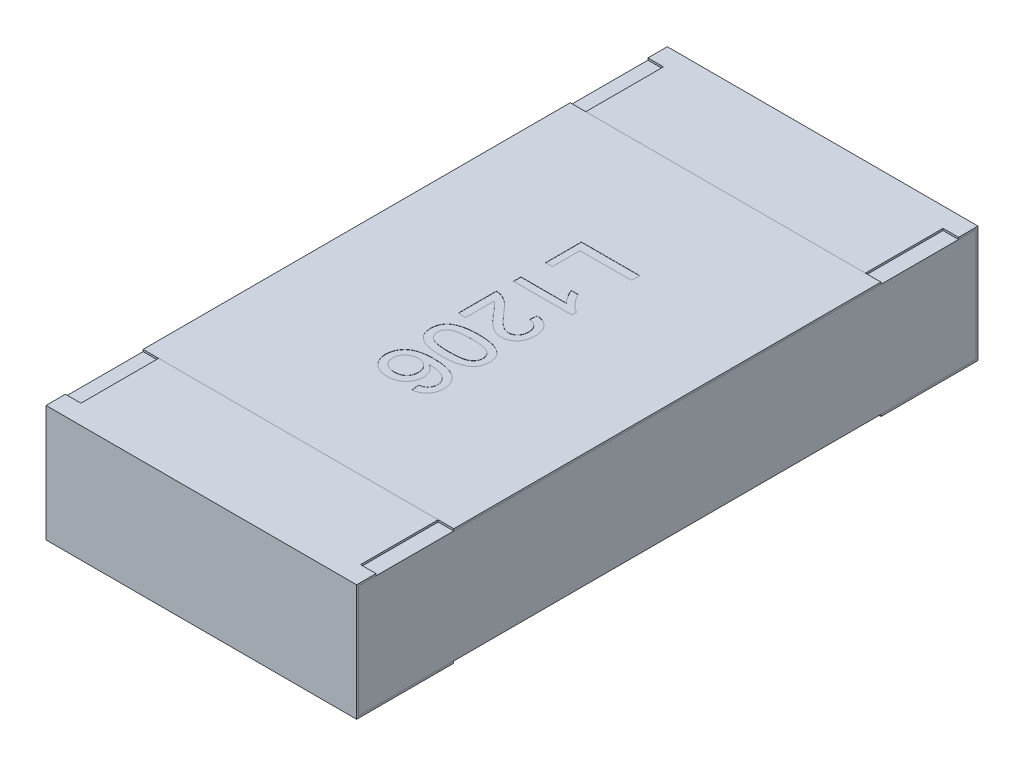
from build123d import *

# Parameters (mm, degrees)
BOSS_EXTRUDE2_DEPTH   = 0.8
BOSS_EXTRUDE2_2_DEPTH = 0.8
BOSS_EXTRUDE3_START   = -0.8
SKETCH5_W             = 3.18
SKETCH5_H             = 0.58
BOSS_EXTRUDE3_DEPTH   = 1.6
SKETCH6_W             = 0.08
SKETCH6_H             = 0.4
CUT_EXTRUDE1_DEPTH    = 0.01
SKETCH7_W             = 1.6
SKETCH7_H             = 2.2
BOSS_EXTRUDE4_DEPTH   = 0.01
TEXT1206_DEPTH        = 0.001


with BuildPart() as part:
    # Sketch4 → Boss-Extrude2 (new body, symmetric)
    with BuildSketch(Plane(origin=(0, 0, 0), x_dir=(0, 0, -1), z_dir=(1, 0, 0))):
        Polygon((-1.6, 0.3), (-1.6, -0.3), (-1.1, -0.3), (-1.1, -0.29), (-1.59, -0.29), (-1.59, 0.29), (-1.1, 0.29), (-1.1, 0.3), align=None)
    extrude(amount=BOSS_EXTRUDE2_DEPTH, both=True)


with BuildPart() as body_2:
    # Sketch4 → Boss-Extrude2 2 (new body, symmetric)
    with BuildSketch(Plane(origin=(0, 0, 0), x_dir=(0, 0, -1), z_dir=(1, 0, 0))):
        Polygon((1.1, 0.3), (1.6, 0.3), (1.6, -0.3), (1.1, -0.3), (1.1, -0.29), (1.59, -0.29), (1.59, 0.29), (1.1, 0.29), align=None)
    extrude(amount=BOSS_EXTRUDE2_2_DEPTH, both=True)


with BuildPart() as body_3:
    # Sketch5 → Boss-Extrude3 (new body)
    with BuildSketch(Plane(origin=(0, 0, 0), x_dir=(0, 0, -1), z_dir=(1, 0, 0)).offset(BOSS_EXTRUDE3_START)):
        Rectangle(SKETCH5_W, SKETCH5_H)
    extrude(amount=BOSS_EXTRUDE3_DEPTH)


with BuildPart() as cut_extrude1_tool:
    # Sketch6 → Cut-Extrude1 (new body)
    with BuildSketch(Plane(origin=(0, 0.3, 0), x_dir=(1, 0, 0), z_dir=(0, 1, 0))):
        with Locations((-0.76, 1.3)):
            Rectangle(SKETCH6_W, SKETCH6_H)
        with Locations((0.76, 1.3)):
            Rectangle(SKETCH6_W, SKETCH6_H)
        with Locations((0.76, -1.3)):
            Rectangle(SKETCH6_W, SKETCH6_H)
        with Locations((-0.76, -1.3)):
            Rectangle(SKETCH6_W, SKETCH6_H)
    extrude(amount=-CUT_EXTRUDE1_DEPTH)


with BuildPart() as part_1:
    add(part.part)

    # Cut-Extrude1: cut by cut_extrude1_tool
    add(cut_extrude1_tool.part, mode=Mode.SUBTRACT)


with BuildPart() as body_2_1:
    add(body_2.part)

    # Cut-Extrude1: cut by cut_extrude1_tool
    add(cut_extrude1_tool.part, mode=Mode.SUBTRACT)


with BuildPart() as body_4:
    # Sketch7 → Boss-Extrude4 (new body)
    with BuildSketch(Plane(origin=(0, 0.29, 0), x_dir=(1, 0, 0), z_dir=(0, 1, 0))):
        Rectangle(SKETCH7_W, SKETCH7_H)
    extrude(amount=BOSS_EXTRUDE4_DEPTH)

    # Sketch12 → TEXT1206 (cut)
    with BuildSketch(Plane(origin=(0, 0.3, 0), x_dir=(1, 0, 0), z_dir=(0, 1, 0))):
        Polygon((-0.15, 0.507688704), (0.15, 0.507688704), (0.15, 0.465381012), (-0.115384615, 0.465381012), (-0.115384615, 0.323073319), (-0.15, 0.323073319), align=None)
        with BuildLine():
            Line((-0.15, 0.157688704), (-0.15, 0.196150243))
            Line((-0.15, 0.196150243), (0.083774038, 0.196150243))
            add(Edge.make_bspline(
                [(0.083774038, 0.196150243), (0.081638509, 0.198364988), (0.077200045, 0.202968095), (0.070914564, 0.210746555), (0.064571645, 0.219426408), (0.058389404, 0.228863662), (0.052683492, 0.2385576), (0.047476916, 0.247897164), (0.043093554, 0.256751905), (0.040694469, 0.262582976), (0.039543269, 0.265381012)],
                knots=[0, 0, 0, 0, 9.226e-06, 1.9175e-05, 2.9969e-05, 4.147e-05, 5.3003e-05, 6.3709e-05, 7.3546e-05, 8.262e-05, 8.262e-05, 8.262e-05, 8.262e-05], degree=3))
            Line((0.039543269, 0.265381012), (0.075, 0.265381012))
            add(Edge.make_bspline(
                [(0.075, 0.265381012), (0.077475162, 0.260574892), (0.082353558, 0.251102313), (0.09077922, 0.237719608), (0.099912985, 0.225225413), (0.10975283, 0.213826557), (0.119810917, 0.203608209), (0.129959923, 0.194997059), (0.139827828, 0.187791796), (0.146709597, 0.184176779), (0.15, 0.182448319)],
                knots=[0, 0, 0, 0, 1.6212e-05, 3.1953e-05, 4.7386e-05, 6.26e-05, 7.7091e-05, 9.0349e-05, 0.000102505, 0.000113642, 0.000113642, 0.000113642, 0.000113642], degree=3))
            Line((0.15, 0.182448319), (0.15, 0.157688704))
            Line((0.15, 0.157688704), (-0.15, 0.157688704))
        make_face()
        with BuildLine():
            Line((-0.111538462, -0.126926681), (-0.15, -0.126926681))
            Line((-0.15, -0.126926681), (-0.15, 0.069227166))
            add(Edge.make_bspline(
                [(-0.15, 0.069227166), (-0.147714123, 0.069231181), (-0.14315003, 0.0692392), (-0.136400026, 0.068466881), (-0.129739566, 0.067257277), (-0.125468478, 0.065889577), (-0.123317308, 0.065200723)],
                knots=[0, 0, 0, 0, 6.852e-06, 1.3681e-05, 2.0352e-05, 2.7121e-05, 2.7121e-05, 2.7121e-05, 2.7121e-05], degree=3))
            add(Edge.make_bspline(
                [(-0.123317308, 0.065200723), (-0.119803316, 0.063926707), (-0.112648251, 0.061332599), (-0.102300861, 0.056097005), (-0.092077121, 0.049836465), (-0.083693742, 0.043844993), (-0.077044802, 0.038326839), (-0.071780052, 0.033776382), (-0.066458477, 0.028650383), (-0.06098519, 0.023042289), (-0.055359875, 0.016986133), (-0.049556317, 0.01048215), (-0.043684824, 0.003451071), (-0.039792869, -0.001457256), (-0.037800481, -0.00396995)],
                knots=[0, 0, 0, 0, 1.1205e-05, 2.2816e-05, 3.4709e-05, 4.7152e-05, 5.3684e-05, 6.0627e-05, 6.8023e-05, 7.5842e-05, 8.4134e-05, 9.2818e-05, 0.00010199, 0.00011161, 0.00011161, 0.00011161, 0.00011161], degree=3))
            add(Edge.make_bspline(
                [(-0.037800481, -0.00396995), (-0.034551471, -0.007830082), (-0.028295295, -0.01526301), (-0.019011711, -0.02575947), (-0.010391377, -0.035346278), (-0.002283205, -0.043870774), (0.005234162, -0.05140268), (0.012143692, -0.057959681), (0.018423822, -0.063598196), (0.024301865, -0.06824939), (0.029852373, -0.072173744), (0.035266551, -0.075499288), (0.040638972, -0.078270688), (0.045952637, -0.080578893), (0.05123027, -0.082404487), (0.056487246, -0.083648889), (0.061671403, -0.084492799), (0.065120999, -0.084577233), (0.066826923, -0.084618988)],
                knots=[0, 0, 0, 0, 1.5136e-05, 2.9145e-05, 4.2036e-05, 5.3811e-05, 6.4435e-05, 7.3957e-05, 8.2386e-05, 8.9745e-05, 9.643e-05, 0.000102769, 0.00010879, 0.00011455, 0.000120137, 0.000125516, 0.000130743, 0.000135857, 0.000135857, 0.000135857, 0.000135857], degree=3))
            add(Edge.make_bspline(
                [(0.066826923, -0.084618988), (0.068512943, -0.084577228), (0.071820821, -0.084495297), (0.076661881, -0.083717941), (0.081323937, -0.082635799), (0.085723062, -0.080886305), (0.089989535, -0.078803882), (0.093988521, -0.076132664), (0.097819766, -0.073042641), (0.101381944, -0.069504724), (0.104724786, -0.065640874), (0.107500012, -0.061322122), (0.110020859, -0.056822609), (0.111988045, -0.051993624), (0.113504097, -0.046878174), (0.114560258, -0.041484466), (0.115243078, -0.035798097), (0.115336721, -0.031916673), (0.115384615, -0.029931488)],
                knots=[0, 0, 0, 0, 5.054e-06, 9.915e-06, 1.4681e-05, 1.938e-05, 2.4083e-05, 2.89e-05, 3.3772e-05, 3.8829e-05, 4.3946e-05, 4.9063e-05, 5.4199e-05, 5.94e-05, 6.4667e-05, 7.0183e-05, 7.587e-05, 8.1825e-05, 8.1825e-05, 8.1825e-05, 8.1825e-05], degree=3))
            add(Edge.make_bspline(
                [(0.115384615, -0.029931488), (0.115336639, -0.027846225), (0.115242746, -0.02376521), (0.114561705, -0.017799215), (0.113515033, -0.012137961), (0.111941815, -0.00680164), (0.109882187, -0.001800923), (0.10742732, 0.002899639), (0.104518024, 0.007282074), (0.101139001, 0.011276251), (0.097458268, 0.014976102), (0.093296561, 0.018101663), (0.088872885, 0.020833831), (0.084046797, 0.022989164), (0.078924308, 0.024746906), (0.073429376, 0.026015652), (0.067585566, 0.026709078), (0.063583419, 0.026848324), (0.061538462, 0.026919473)],
                knots=[0, 0, 0, 0, 6.255e-06, 1.2241e-05, 1.7992e-05, 2.3507e-05, 2.8897e-05, 3.4193e-05, 3.9393e-05, 4.4641e-05, 4.9868e-05, 5.5012e-05, 6.0217e-05, 6.5434e-05, 7.0832e-05, 7.6444e-05, 8.2318e-05, 8.8455e-05, 8.8455e-05, 8.8455e-05, 8.8455e-05], degree=3))
            Line((0.061538462, 0.026919473), (0.065384615, 0.065381012))
            add(Edge.make_bspline(
                [(0.065384615, 0.065381012), (0.068736662, 0.064987537), (0.07525778, 0.064222066), (0.084702032, 0.06231461), (0.093489714, 0.059639541), (0.101734943, 0.05642903), (0.109336857, 0.052433668), (0.116323186, 0.047801811), (0.122725854, 0.042537069), (0.12839596, 0.036547762), (0.133571363, 0.03006313), (0.137925688, 0.02292231), (0.141698648, 0.01529096), (0.144749435, 0.007114765), (0.147087025, -0.001603064), (0.148758415, -0.010848952), (0.149789925, -0.020633362), (0.149928976, -0.027344786), (0.15, -0.030772834)],
                knots=[0, 0, 0, 0, 1.0123e-05, 1.9693e-05, 2.8857e-05, 3.7651e-05, 4.6199e-05, 5.4566e-05, 6.276e-05, 7.1006e-05, 7.9266e-05, 8.7604e-05, 9.6043e-05, 0.000104772, 0.000113738, 0.000123085, 0.000132934, 0.000143217, 0.000143217, 0.000143217, 0.000143217], degree=3))
            add(Edge.make_bspline(
                [(0.15, -0.030772834), (0.149940576, -0.034241888), (0.149824817, -0.040999626), (0.148641062, -0.050846917), (0.146795931, -0.06013743), (0.144229333, -0.068908348), (0.140839664, -0.077113074), (0.136757117, -0.084779699), (0.131911514, -0.091883946), (0.126324053, -0.098329373), (0.120221623, -0.104141791), (0.113705953, -0.109228045), (0.106829733, -0.113504119), (0.099612825, -0.117041018), (0.092008541, -0.119749254), (0.084045391, -0.121634003), (0.075742745, -0.122920552), (0.070077161, -0.123026493), (0.0671875, -0.123080527)],
                knots=[0, 0, 0, 0, 1.0403e-05, 2.0265e-05, 2.9705e-05, 3.8794e-05, 4.7633e-05, 5.6291e-05, 6.4808e-05, 7.3373e-05, 8.1833e-05, 9.0055e-05, 9.8126e-05, 0.000106082, 0.000114122, 0.000122285, 0.000130605, 0.000139266, 0.000139266, 0.000139266, 0.000139266], degree=3))
            add(Edge.make_bspline(
                [(0.0671875, -0.123080527), (0.064218398, -0.122999413), (0.05827364, -0.122837007), (0.049399233, -0.121521732), (0.040594357, -0.119404536), (0.03178904, -0.116466766), (0.02297561, -0.112378321), (0.013942435, -0.107343077), (0.004756402, -0.101049705), (-0.003111225, -0.095081455), (-0.009660413, -0.089462191), (-0.015062592, -0.084481388), (-0.020824791, -0.078720309), (-0.027059821, -0.072332158), (-0.033675497, -0.065186093), (-0.04077151, -0.057412334), (-0.048197577, -0.048856481), (-0.053269547, -0.042915902), (-0.055889423, -0.039847354)],
                knots=[0, 0, 0, 0, 8.904e-06, 1.7828e-05, 2.6851e-05, 3.6049e-05, 4.5623e-05, 5.5954e-05, 6.7039e-05, 7.8998e-05, 8.5562e-05, 9.292e-05, 0.000101036, 0.000110004, 0.000119698, 0.000130249, 0.000141579, 0.000153683, 0.000153683, 0.000153683, 0.000153683], degree=3))
            add(Edge.make_bspline(
                [(-0.055889423, -0.039847354), (-0.058028577, -0.037219656), (-0.062107615, -0.032209042), (-0.068021764, -0.025081042), (-0.073442596, -0.018694552), (-0.07820298, -0.012908717), (-0.082492694, -0.007919578), (-0.086224809, -0.003620127), (-0.089451821, -5.3055e-05), (-0.094402484, 0.005384763), (-0.10140021, 0.012324432), (-0.108253196, 0.01739658), (-0.111538462, 0.019828127)],
                knots=[0, 0, 0, 0, 1.0165e-05, 1.9383e-05, 2.7786e-05, 3.5295e-05, 4.1859e-05, 4.7524e-05, 5.2375e-05, 5.6288e-05, 6.9591e-05, 8.184e-05, 8.184e-05, 8.184e-05, 8.184e-05], degree=3))
            Line((-0.111538462, 0.019828127), (-0.111538462, -0.126926681))
        make_face()
        with BuildLine():
            add(Edge.make_bspline(
                [(-0.002043269, -0.169234373), (0.002244006, -0.169273123), (0.010640973, -0.169349018), (0.022927245, -0.169819769), (0.034595007, -0.170641665), (0.045634132, -0.171868522), (0.05606952, -0.173321372), (0.065886336, -0.175210012), (0.075106414, -0.177335253), (0.083720798, -0.179884297), (0.091801288, -0.182687793), (0.099342803, -0.18585815), (0.106300734, -0.189456581), (0.112864039, -0.193158601), (0.118725274, -0.1974687), (0.12425569, -0.201839658), (0.129139599, -0.206718518), (0.133536862, -0.211873239), (0.137415967, -0.217389249), (0.140763485, -0.223234868), (0.143719015, -0.229388265), (0.145943958, -0.23596654), (0.147757752, -0.242833175), (0.149092003, -0.250041015), (0.149878588, -0.257598005), (0.149959072, -0.262762146), (0.15, -0.265388219)],
                knots=[0, 0, 0, 0, 1.2862e-05, 2.5191e-05, 3.688e-05, 4.7943e-05, 5.8507e-05, 6.8478e-05, 7.7924e-05, 8.6881e-05, 9.5415e-05, 0.000103574, 0.000111395, 0.000118909, 0.000126147, 0.000133195, 0.000140037, 0.000146816, 0.000153502, 0.000160233, 0.000167008, 0.000173945, 0.000181029, 0.000188302, 0.000195914, 0.00020379, 0.00020379, 0.00020379, 0.00020379], degree=3))
            add(Edge.make_bspline(
                [(0.15, -0.265388219), (0.149886629, -0.269240941), (0.149663908, -0.276809769), (0.147850494, -0.287861472), (0.144740696, -0.298272516), (0.140578188, -0.308041271), (0.135193656, -0.316956509), (0.128816305, -0.325016713), (0.121179131, -0.331896216), (0.11253276, -0.337822266), (0.102860028, -0.342903854), (0.092252026, -0.347449543), (0.080663785, -0.351525176), (0.070320072, -0.354508362), (0.061375886, -0.356599839), (0.053985027, -0.35787319), (0.046034731, -0.359048861), (0.03750596, -0.359882193), (0.028438575, -0.360730176), (0.018793038, -0.361148836), (0.008575899, -0.361468335), (0.001562812, -0.361517028), (-0.002043269, -0.361542065)],
                knots=[0, 0, 0, 0, 1.1554e-05, 2.2698e-05, 3.348e-05, 4.4085e-05, 5.4464e-05, 6.4638e-05, 7.4805e-05, 8.5173e-05, 9.6008e-05, 0.000107529, 0.00011977, 0.000132837, 0.000139806, 0.000147315, 0.000155329, 0.00016391, 0.000173019, 0.000182646, 0.000192867, 0.000203685, 0.000203685, 0.000203685, 0.000203685], degree=3))
            add(Edge.make_bspline(
                [(-0.002043269, -0.361542065), (-0.00631044, -0.361502808), (-0.014647199, -0.361426111), (-0.026834487, -0.360964938), (-0.03841587, -0.360104202), (-0.049405471, -0.358995019), (-0.059813481, -0.357501643), (-0.069614428, -0.355635096), (-0.078820333, -0.35347923), (-0.087440482, -0.351039573), (-0.095486737, -0.348201209), (-0.102997606, -0.34499991), (-0.110046684, -0.341567172), (-0.116502689, -0.337673514), (-0.122472492, -0.333526537), (-0.127974887, -0.329087497), (-0.132931669, -0.324264447), (-0.137314485, -0.319061611), (-0.141263346, -0.313584977), (-0.144641302, -0.307724168), (-0.147459366, -0.301492893), (-0.149814671, -0.29494669), (-0.151604655, -0.288042108), (-0.15293367, -0.280815122), (-0.153727476, -0.273218584), (-0.153806049, -0.268034352), (-0.153846154, -0.265388219)],
                knots=[0, 0, 0, 0, 1.2802e-05, 2.5011e-05, 3.658e-05, 4.7637e-05, 5.8141e-05, 6.8112e-05, 7.7558e-05, 8.6498e-05, 9.4975e-05, 0.000103135, 0.000110983, 0.000118475, 0.000125727, 0.000132776, 0.000139661, 0.00014644, 0.00015316, 0.000159891, 0.000166695, 0.000173652, 0.000180737, 0.000188068, 0.000195681, 0.000203617, 0.000203617, 0.000203617, 0.000203617], degree=3))
            add(Edge.make_bspline(
                [(-0.153846154, -0.265388219), (-0.153747192, -0.261918909), (-0.153554242, -0.25515471), (-0.152243272, -0.245276096), (-0.149935902, -0.236004489), (-0.146841394, -0.22726169), (-0.142702311, -0.219145969), (-0.137666308, -0.211618578), (-0.131850554, -0.204528258), (-0.127262057, -0.20044664), (-0.124939904, -0.198381007)],
                knots=[0, 0, 0, 0, 1.0408e-05, 2.0292e-05, 2.9825e-05, 3.9025e-05, 4.8056e-05, 5.7073e-05, 6.616e-05, 7.5471e-05, 7.5471e-05, 7.5471e-05, 7.5471e-05], degree=3))
            add(Edge.make_bspline(
                [(-0.124939904, -0.198381007), (-0.121510195, -0.196003417), (-0.11443799, -0.191100725), (-0.102379223, -0.185362549), (-0.089104214, -0.180243994), (-0.074352508, -0.176226867), (-0.058241513, -0.173080455), (-0.040739616, -0.17080796), (-0.021854376, -0.169521951), (-0.008796046, -0.169332396), (-0.002043269, -0.169234373)],
                knots=[0, 0, 0, 0, 1.2501e-05, 2.5778e-05, 3.993e-05, 5.5152e-05, 7.157e-05, 8.9147e-05, 0.000108063, 0.000128321, 0.000128321, 0.000128321, 0.000128321], degree=3))
        make_face()
        with BuildLine():
            add(Edge.make_bspline(
                [(-0.001923077, -0.207695911), (-0.007693168, -0.207734101), (-0.018738399, -0.207807203), (-0.034518417, -0.208570949), (-0.048754147, -0.209885705), (-0.061425879, -0.211623899), (-0.072550754, -0.213919018), (-0.082100422, -0.216800812), (-0.090189501, -0.22004928), (-0.096717734, -0.224069197), (-0.102039196, -0.228470561), (-0.106615825, -0.23301467), (-0.110505855, -0.237808429), (-0.113749347, -0.24282056), (-0.116205105, -0.24812883), (-0.117985045, -0.253675194), (-0.119009373, -0.259460859), (-0.119156549, -0.263401159), (-0.119230769, -0.265388219)],
                knots=[0, 0, 0, 0, 1.7309e-05, 3.3134e-05, 4.7378e-05, 6.0186e-05, 7.1489e-05, 8.1413e-05, 9.0085e-05, 9.7558e-05, 0.000104306, 0.000110765, 0.000116876, 0.000122794, 0.000128628, 0.000134368, 0.000140227, 0.000146187, 0.000146187, 0.000146187, 0.000146187], degree=3))
            add(Edge.make_bspline(
                [(-0.119230769, -0.265388219), (-0.119154928, -0.267374781), (-0.119004535, -0.271314095), (-0.118002795, -0.277113128), (-0.116131225, -0.282637912), (-0.11368414, -0.287938267), (-0.110514577, -0.292986828), (-0.106609854, -0.297757044), (-0.102035942, -0.30232509), (-0.096652628, -0.306706684), (-0.090094213, -0.310695974), (-0.082011723, -0.314005379), (-0.072445331, -0.316842262), (-0.061326124, -0.319149975), (-0.048674427, -0.320895339), (-0.03447818, -0.322202147), (-0.018718466, -0.322971003), (-0.007693194, -0.3230429), (-0.001923077, -0.323080527)],
                knots=[0, 0, 0, 0, 5.96e-06, 1.1819e-05, 1.7578e-05, 2.3412e-05, 2.9298e-05, 3.5408e-05, 4.1867e-05, 4.8662e-05, 5.6186e-05, 6.4803e-05, 7.4784e-05, 8.6088e-05, 9.8836e-05, 0.00011308, 0.000128845, 0.000146154, 0.000146154, 0.000146154, 0.000146154], degree=3))
            add(Edge.make_bspline(
                [(-0.001923077, -0.323080527), (0.003726983, -0.323044105), (0.014552285, -0.322974322), (0.030028294, -0.322185629), (0.044025103, -0.320949706), (0.056555506, -0.319259069), (0.067606248, -0.317012499), (0.077199767, -0.314286852), (0.085318952, -0.311041481), (0.09203502, -0.307174598), (0.097578912, -0.302887122), (0.102284051, -0.29833179), (0.106407321, -0.293596755), (0.109635927, -0.28841143), (0.11228385, -0.282996252), (0.114056455, -0.277235136), (0.1151941, -0.271202471), (0.115320181, -0.267076252), (0.115384615, -0.264967546)],
                knots=[0, 0, 0, 0, 1.6949e-05, 3.2473e-05, 4.6473e-05, 5.9094e-05, 7.0385e-05, 8.0274e-05, 8.8979e-05, 9.6545e-05, 0.000103444, 0.000109947, 0.000116172, 0.000122224, 0.000128218, 0.000134205, 0.000140252, 0.000146573, 0.000146573, 0.000146573, 0.000146573], degree=3))
            add(Edge.make_bspline(
                [(0.115384615, -0.264967546), (0.115332466, -0.262980611), (0.115229635, -0.259062629), (0.114248109, -0.253326191), (0.112606778, -0.247889836), (0.110383437, -0.242691281), (0.107391258, -0.237860305), (0.103897677, -0.233205324), (0.099641138, -0.228944359), (0.096459016, -0.226376739), (0.094831731, -0.2250637)],
                knots=[0, 0, 0, 0, 5.957e-06, 1.1747e-05, 1.7393e-05, 2.2965e-05, 2.8654e-05, 3.4399e-05, 4.0391e-05, 4.6662e-05, 4.6662e-05, 4.6662e-05, 4.6662e-05], degree=3))
            add(Edge.make_bspline(
                [(0.094831731, -0.2250637), (0.092441753, -0.223634201), (0.087394622, -0.2206154), (0.078622501, -0.217237537), (0.068597636, -0.214253666), (0.057165788, -0.211796952), (0.044346567, -0.210019691), (0.03015486, -0.208616612), (0.014570853, -0.207887765), (0.003726591, -0.207761627), (-0.001923077, -0.207695911)],
                knots=[0, 0, 0, 0, 8.341e-06, 1.7615e-05, 2.8091e-05, 3.9714e-05, 5.2649e-05, 6.6899e-05, 8.2483e-05, 9.9433e-05, 9.9433e-05, 9.9433e-05, 9.9433e-05], degree=3))
        make_face(mode=Mode.SUBTRACT)
        with BuildLine():
            Line((0.073076923, -0.588465142), (0.069230769, -0.550003604))
            add(Edge.make_bspline(
                [(0.069230769, -0.550003604), (0.072538667, -0.549173635), (0.078765275, -0.547611346), (0.087210729, -0.54433524), (0.094354147, -0.540725042), (0.09820068, -0.537588564), (0.1, -0.536121392)],
                knots=[0, 0, 0, 0, 1.022e-05, 1.9238e-05, 2.7142e-05, 3.4089e-05, 3.4089e-05, 3.4089e-05, 3.4089e-05], degree=3))
            add(Edge.make_bspline(
                [(0.1, -0.536121392), (0.101227235, -0.534861996), (0.103640922, -0.532385054), (0.10678718, -0.528318818), (0.109452847, -0.524032331), (0.111612442, -0.51951264), (0.113318398, -0.51478416), (0.114511805, -0.509827307), (0.115250592, -0.504653308), (0.115339561, -0.501127874), (0.115384615, -0.499342546)],
                knots=[0, 0, 0, 0, 5.272e-06, 1.0369e-05, 1.5389e-05, 2.0388e-05, 2.5369e-05, 3.0441e-05, 3.5659e-05, 4.1013e-05, 4.1013e-05, 4.1013e-05, 4.1013e-05], degree=3))
            add(Edge.make_bspline(
                [(0.115384615, -0.499342546), (0.115291422, -0.496448221), (0.115107275, -0.490729163), (0.113304494, -0.482338282), (0.110606344, -0.474188377), (0.107871213, -0.46913921), (0.106490385, -0.466590142)],
                knots=[0, 0, 0, 0, 8.671e-06, 1.7133e-05, 2.5647e-05, 3.4328e-05, 3.4328e-05, 3.4328e-05, 3.4328e-05], degree=3))
            add(Edge.make_bspline(
                [(0.106490385, -0.466590142), (0.10441265, -0.464084446), (0.100147558, -0.458940853), (0.092289965, -0.452213636), (0.083077394, -0.446290677), (0.074540242, -0.441835593), (0.066846581, -0.43874572), (0.060290972, -0.436633114), (0.053006364, -0.434937894), (0.045063657, -0.433494417), (0.036435089, -0.432387194), (0.027119809, -0.431458862), (0.017092814, -0.430946066), (0.01017678, -0.43083177), (0.006610577, -0.430772834)],
                knots=[0, 0, 0, 0, 9.752e-06, 2.0019e-05, 3.087e-05, 4.2561e-05, 4.8844e-05, 5.5724e-05, 6.3202e-05, 7.1264e-05, 7.9934e-05, 8.9292e-05, 9.9343e-05, 0.000110043, 0.000110043, 0.000110043, 0.000110043], degree=3))
            add(Edge.make_bspline(
                [(0.006610577, -0.430772834), (0.009795477, -0.433041154), (0.016030114, -0.437481529), (0.024212744, -0.445312295), (0.031067161, -0.453915984), (0.036597117, -0.46319793), (0.04084587, -0.472953076), (0.043940923, -0.482964724), (0.045813696, -0.493242759), (0.046039886, -0.500176227), (0.046153846, -0.503669469)],
                knots=[0, 0, 0, 0, 1.1719e-05, 2.294e-05, 3.3846e-05, 4.4627e-05, 5.5256e-05, 6.5692e-05, 7.6007e-05, 8.6481e-05, 8.6481e-05, 8.6481e-05, 8.6481e-05], degree=3))
            add(Edge.make_bspline(
                [(0.046153846, -0.503669469), (0.046073141, -0.506678263), (0.045913693, -0.512622709), (0.044642775, -0.521374887), (0.042443894, -0.529753986), (0.039510539, -0.537838013), (0.03561771, -0.545520002), (0.030986977, -0.552930346), (0.025382922, -0.559904439), (0.019081048, -0.566535601), (0.012076169, -0.572573587), (0.004536554, -0.577917482), (-0.003555427, -0.582370778), (-0.012145697, -0.585981877), (-0.021202967, -0.588808195), (-0.030752967, -0.59086185), (-0.040814567, -0.592064032), (-0.047693081, -0.59222777), (-0.051201923, -0.592311296)],
                knots=[0, 0, 0, 0, 9.024e-06, 1.7829e-05, 2.6458e-05, 3.4976e-05, 4.3576e-05, 5.2246e-05, 6.1144e-05, 7.0367e-05, 7.9656e-05, 8.8843e-05, 9.8042e-05, 0.000107306, 0.000116753, 0.000126465, 0.000136573, 0.000147098, 0.000147098, 0.000147098, 0.000147098], degree=3))
            add(Edge.make_bspline(
                [(-0.051201923, -0.592311296), (-0.055838732, -0.592160837), (-0.064989364, -0.59186391), (-0.078471794, -0.589505194), (-0.0914327, -0.585643604), (-0.101789083, -0.581212466), (-0.109589893, -0.576887823), (-0.115155958, -0.573414496), (-0.120335333, -0.569592493), (-0.125221374, -0.565546675), (-0.12965227, -0.561100629), (-0.133846599, -0.55650938), (-0.137559741, -0.551517944), (-0.14100293, -0.546328631), (-0.143981548, -0.540835346), (-0.146648405, -0.535191375), (-0.14887735, -0.529344352), (-0.150664912, -0.523309932), (-0.152128372, -0.517115184), (-0.15313727, -0.510727766), (-0.153758817, -0.504162787), (-0.153816816, -0.499724554), (-0.153846154, -0.497479565)],
                knots=[0, 0, 0, 0, 1.3904e-05, 2.744e-05, 4.0921e-05, 5.4406e-05, 6.1131e-05, 6.7667e-05, 7.4073e-05, 8.0429e-05, 8.6676e-05, 9.2889e-05, 9.9067e-05, 0.000105318, 0.000111558, 0.000117795, 0.000124034, 0.000130308, 0.000136664, 0.000143115, 0.000149693, 0.000156427, 0.000156427, 0.000156427, 0.000156427], degree=3))
            add(Edge.make_bspline(
                [(-0.153846154, -0.497479565), (-0.153740754, -0.493688296), (-0.153534047, -0.486252952), (-0.151953702, -0.475368424), (-0.149288315, -0.465021813), (-0.145633365, -0.455195097), (-0.140909903, -0.445909509), (-0.135075633, -0.437197255), (-0.12820275, -0.42902084), (-0.120287752, -0.42136871), (-0.111121362, -0.414456054), (-0.100618232, -0.408429791), (-0.088691171, -0.403493657), (-0.075489024, -0.399324493), (-0.060886894, -0.396237734), (-0.044979101, -0.393857171), (-0.027704336, -0.392605061), (-0.015746934, -0.392411516), (-0.009555288, -0.392311296)],
                knots=[0, 0, 0, 0, 1.1371e-05, 2.2301e-05, 3.2912e-05, 4.3371e-05, 5.3692e-05, 6.4092e-05, 7.4757e-05, 8.568e-05, 9.705e-05, 0.000109111, 0.000121902, 0.000135701, 0.000150589, 0.000166627, 0.000183925, 0.000202501, 0.000202501, 0.000202501, 0.000202501], degree=3))
            add(Edge.make_bspline(
                [(-0.009555288, -0.392311296), (-0.006029435, -0.392335473), (0.000923993, -0.392383152), (0.011166388, -0.392726559), (0.02104414, -0.393403677), (0.030544369, -0.394293693), (0.039682284, -0.395440435), (0.048451962, -0.396786523), (0.056841129, -0.398503934), (0.064868317, -0.400393584), (0.072539039, -0.402585721), (0.07986297, -0.40494144), (0.086786449, -0.407675472), (0.093351424, -0.410609891), (0.099548274, -0.413803035), (0.105400821, -0.41720246), (0.110833989, -0.420960235), (0.114237069, -0.423662765), (0.115925481, -0.425003604)],
                knots=[0, 0, 0, 0, 1.0578e-05, 2.086e-05, 3.0738e-05, 4.0276e-05, 4.9482e-05, 5.8364e-05, 6.6885e-05, 7.5165e-05, 8.3098e-05, 9.0813e-05, 9.8235e-05, 0.000105417, 0.000112378, 0.000119139, 0.000125707, 0.000132174, 0.000132174, 0.000132174, 0.000132174], degree=3))
            add(Edge.make_bspline(
                [(0.115925481, -0.425003604), (0.118650597, -0.427426353), (0.124022054, -0.432201818), (0.130960705, -0.440371137), (0.136887379, -0.449076234), (0.14167562, -0.458455946), (0.145408685, -0.468438582), (0.14811856, -0.479030401), (0.149690101, -0.490260959), (0.149895026, -0.49793534), (0.15, -0.501866584)],
                knots=[0, 0, 0, 0, 1.0928e-05, 2.154e-05, 3.2057e-05, 4.2459e-05, 5.3051e-05, 6.3969e-05, 7.5196e-05, 8.6987e-05, 8.6987e-05, 8.6987e-05, 8.6987e-05], degree=3))
            add(Edge.make_bspline(
                [(0.15, -0.501866584), (0.149948255, -0.504793832), (0.149846599, -0.510544647), (0.148871193, -0.518971058), (0.147240948, -0.526986056), (0.145041931, -0.534607492), (0.142114758, -0.54179105), (0.138645741, -0.548619546), (0.134472732, -0.555023644), (0.129652743, -0.560956981), (0.124322407, -0.566434254), (0.118436964, -0.571340171), (0.112069766, -0.575656247), (0.10520757, -0.579416234), (0.097882861, -0.582586534), (0.090064157, -0.585189508), (0.081753468, -0.587167942), (0.076009194, -0.588026748), (0.073076923, -0.588465142)],
                knots=[0, 0, 0, 0, 8.779e-06, 1.7247e-05, 2.5403e-05, 3.3295e-05, 4.1006e-05, 4.864e-05, 5.624e-05, 6.389e-05, 7.1539e-05, 7.9134e-05, 8.6834e-05, 9.458e-05, 0.000102574, 0.000110746, 0.000119273, 0.000128165, 0.000128165, 0.000128165, 0.000128165], degree=3))
        make_face()
        with BuildLine():
            add(Edge.make_bspline(
                [(-0.050420673, -0.430772834), (-0.053432194, -0.430879814), (-0.0594157, -0.431092368), (-0.068297189, -0.432718164), (-0.076962701, -0.435373203), (-0.085315996, -0.439011966), (-0.093077055, -0.443505167), (-0.099953889, -0.448842043), (-0.105845529, -0.454906751), (-0.110764759, -0.461666698), (-0.114545052, -0.469106017), (-0.117282967, -0.477091467), (-0.118937772, -0.48563259), (-0.119131628, -0.491522611), (-0.119230769, -0.494534854)],
                knots=[0, 0, 0, 0, 9.031e-06, 1.7943e-05, 2.6992e-05, 3.6169e-05, 4.5219e-05, 5.3826e-05, 6.2198e-05, 7.0505e-05, 7.881e-05, 8.7134e-05, 9.5761e-05, 0.000104792, 0.000104792, 0.000104792, 0.000104792], degree=3))
            add(Edge.make_bspline(
                [(-0.119230769, -0.494534854), (-0.119172977, -0.49668152), (-0.119060171, -0.500871624), (-0.118178429, -0.507004907), (-0.11684577, -0.512844871), (-0.114806117, -0.5183641), (-0.112309347, -0.523601035), (-0.10918855, -0.528529603), (-0.105531209, -0.533151142), (-0.101314299, -0.537415794), (-0.096625632, -0.541270623), (-0.091492468, -0.544619824), (-0.085999671, -0.547577519), (-0.080012146, -0.549802169), (-0.073683317, -0.551614939), (-0.066953335, -0.55294767), (-0.059814476, -0.553730124), (-0.05490983, -0.553809302), (-0.052403846, -0.553849757)],
                knots=[0, 0, 0, 0, 6.437e-06, 1.2565e-05, 1.8556e-05, 2.4373e-05, 3.0179e-05, 3.5931e-05, 4.1835e-05, 4.7827e-05, 5.389e-05, 6.0007e-05, 6.619e-05, 7.2563e-05, 7.9125e-05, 8.5926e-05, 9.312e-05, 0.000100636, 0.000100636, 0.000100636, 0.000100636], degree=3))
            add(Edge.make_bspline(
                [(-0.052403846, -0.553849757), (-0.049997405, -0.5538122), (-0.045291307, -0.553738752), (-0.038423791, -0.552913591), (-0.031932743, -0.551709027), (-0.025867365, -0.549868801), (-0.020191383, -0.547584021), (-0.014868585, -0.544830342), (-0.009963369, -0.541505252), (-0.00552858, -0.537632394), (-0.001495686, -0.533386952), (0.002032766, -0.528721284), (0.004957271, -0.523659589), (0.007401763, -0.518252544), (0.009256081, -0.512462277), (0.010544722, -0.506297522), (0.011443245, -0.499789459), (0.011506236, -0.495319312), (0.011538462, -0.49303245)],
                knots=[0, 0, 0, 0, 7.216e-06, 1.4111e-05, 2.0723e-05, 2.6997e-05, 3.309e-05, 3.9058e-05, 4.4942e-05, 5.0821e-05, 5.6688e-05, 6.2481e-05, 6.8325e-05, 7.4189e-05, 8.0252e-05, 8.6523e-05, 9.3067e-05, 9.9922e-05, 9.9922e-05, 9.9922e-05, 9.9922e-05], degree=3))
            add(Edge.make_bspline(
                [(0.011538462, -0.49303245), (0.011505256, -0.490905638), (0.011439821, -0.486714554), (0.010533652, -0.480568551), (0.009244727, -0.474644062), (0.007363031, -0.468969387), (0.004970004, -0.463541347), (0.001968126, -0.458392947), (-0.001495081, -0.453454612), (-0.005537262, -0.448859116), (-0.009918452, -0.444604765), (-0.014718804, -0.440899197), (-0.019847252, -0.437779279), (-0.025301739, -0.435140025), (-0.031124545, -0.433188986), (-0.03726742, -0.431806377), (-0.043725843, -0.430947799), (-0.048154343, -0.430832063), (-0.050420673, -0.430772834)],
                knots=[0, 0, 0, 0, 6.375e-06, 1.2562e-05, 1.8598e-05, 2.4546e-05, 3.0465e-05, 3.6361e-05, 4.2397e-05, 4.8531e-05, 5.4694e-05, 6.0692e-05, 6.6681e-05, 7.2675e-05, 7.8832e-05, 8.5057e-05, 9.1543e-05, 9.834e-05, 9.834e-05, 9.834e-05, 9.834e-05], degree=3))
        make_face(mode=Mode.SUBTRACT)
    extrude(amount=-TEXT1206_DEPTH, mode=Mode.SUBTRACT)


solid = Compound([body_3.part, part_1.part, body_2_1.part, body_4.part])
